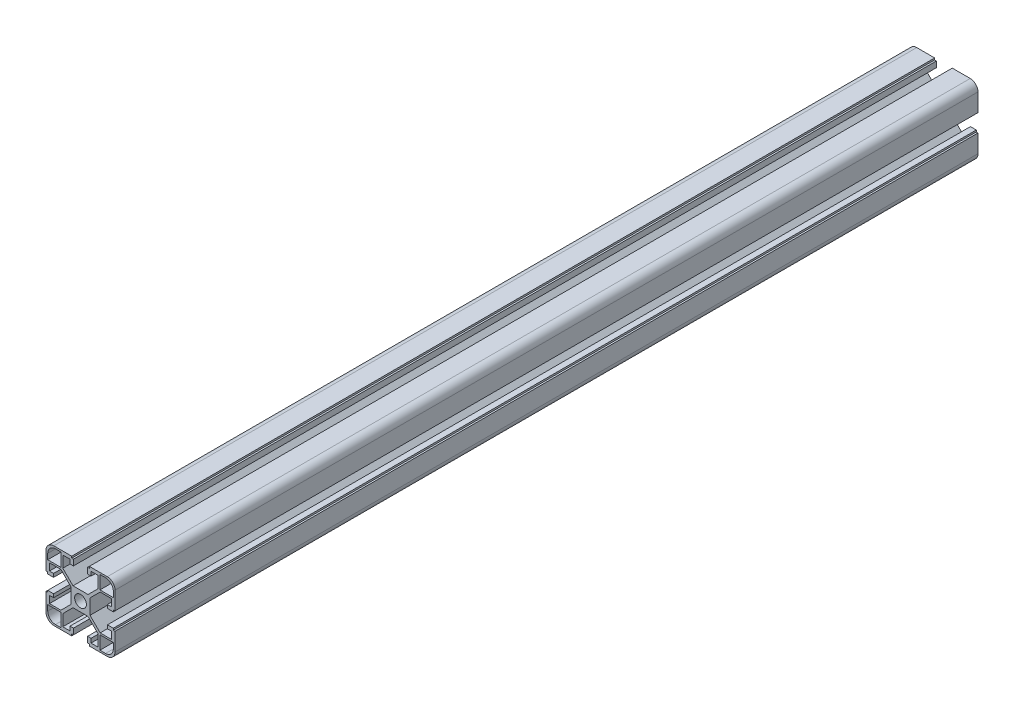
from build123d import *

# Parameters (mm, degrees)
SKETCH_1_W          = 40
SKETCH_1_H          = 40
EXTRUDE_1_DEPTH     = 500
CUT_EXTRUDE_1_DEPTH = 501
SKETCH_3_W          = 7.75
SKETCH_3_H          = 7.75
CUT_EXTRUDE_2_DEPTH = 501
SKETCH_4_R          = 3.4
CUT_EXTRUDE_3_DEPTH = 501
FILLET_1_R          = 4.5


with BuildPart() as part:
    # 草图1 → 凸台-拉伸1 (new body)
    with BuildSketch(Plane.XY):
        Rectangle(SKETCH_1_W, SKETCH_1_H)
    extrude(amount=-EXTRUDE_1_DEPTH)

    # 草图2 → 切除-拉伸1 (cut, through all)
    with BuildSketch(Plane.XY):
        Polygon((-19, 5.1), (-20, 5.1), (-20, -5.1), (-19, -5.1), (-19, -4.1), (-15.6, -4.1), (-15.6, -6.1), (-18, -6.1), (-18, -10.25), (-11.38137085, -10.25), (-5.5, -4.36862915), (-5.5, 4.36862915), (-11.38137085, 10.25), (-18, 10.25), (-18, 6.1), (-15.6, 6.1), (-15.6, 4.1), (-19, 4.1), align=None)
        Polygon((-5.1, -19), (-5.1, -20), (5.1, -20), (5.1, -19), (4.1, -19), (4.1, -15.6), (6.1, -15.6), (6.1, -18), (10.25, -18), (10.25, -11.38137085), (4.36862915, -5.5), (-4.36862915, -5.5), (-10.25, -11.38137085), (-10.25, -18), (-6.1, -18), (-6.1, -15.6), (-4.1, -15.6), (-4.1, -19), align=None)
        Polygon((20, -5.1), (20, 5.1), (19, 5.1), (19, 4.1), (15.6, 4.1), (15.6, 6.1), (18, 6.1), (18, 10.25), (11.38137085, 10.25), (5.5, 4.36862915), (5.5, -4.36862915), (11.38137085, -10.25), (18, -10.25), (18, -6.1), (15.6, -6.1), (15.6, -4.1), (19, -4.1), (19, -5.1), align=None)
        Polygon((5.1, 20), (-5.1, 20), (-5.1, 19), (-4.1, 19), (-4.1, 15.6), (-6.1, 15.6), (-6.1, 18), (-10.25, 18), (-10.25, 11.38137085), (-4.36862915, 5.5), (4.36862915, 5.5), (10.25, 11.38137085), (10.25, 18), (6.1, 18), (6.1, 15.6), (4.1, 15.6), (4.1, 19), (5.1, 19), align=None)
    extrude(amount=-CUT_EXTRUDE_1_DEPTH, mode=Mode.SUBTRACT)

    # 草图3 → 切除-拉伸2 (cut, through all)
    with BuildSketch(Plane.XY):
        with Locations((-15.125, 15.125)):
            Rectangle(SKETCH_3_W, SKETCH_3_H)
        with Locations((15.125, 15.125)):
            Rectangle(SKETCH_3_W, SKETCH_3_H)
        with Locations((15.125, -15.125)):
            Rectangle(SKETCH_3_W, SKETCH_3_H)
        with Locations((-15.125, -15.125)):
            Rectangle(SKETCH_3_W, SKETCH_3_H)
    extrude(amount=-CUT_EXTRUDE_2_DEPTH, mode=Mode.SUBTRACT)

    # 草图4 → 切除-拉伸3 (cut, through all)
    with BuildSketch(Plane.XY):
        Circle(SKETCH_4_R)
    extrude(amount=-CUT_EXTRUDE_3_DEPTH, mode=Mode.SUBTRACT)

    # 圆角1
    fillet_1_edges = [part.edges().sort_by_distance(p)[0] for p in [
        (-19, -19, -250),
        (19, -19, -250),
        (19, 19, -250),
        (-19, 19, -250),
        (20, -20, -250),
        (-20, -20, -250),
        (-20, 20, -250),
        (20, 20, -250),
    ]]
    fillet(fillet_1_edges, radius=FILLET_1_R)


solid = part.part
